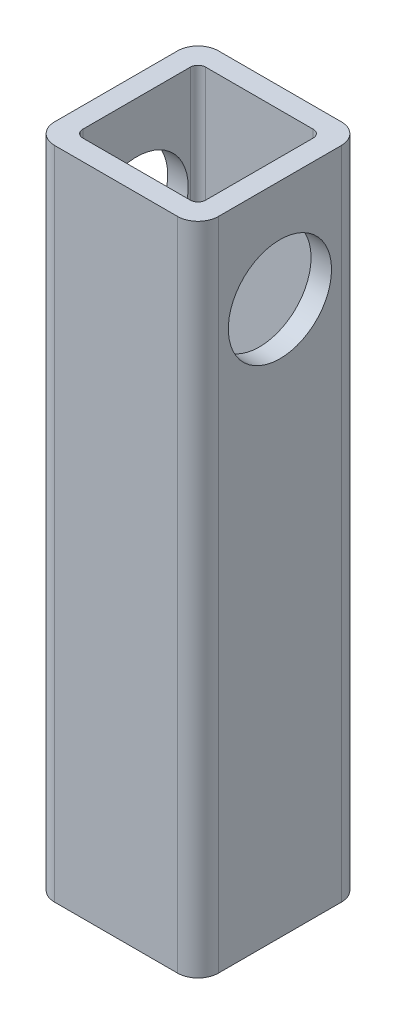
from build123d import *

# Parameters (mm, degrees)
BOSS_EXTRUDE1_DEPTH = 101.6
SKETCH2_R           = 16.002
CUT_EXTRUDE1_DEPTH  = 51.8


with BuildPart() as part:
    # Sketch1 → Boss-Extrude1 (new body, symmetric)
    with BuildSketch(Plane(origin=(0, 0, 0), x_dir=(0, 0, -1), z_dir=(0, 1, 0))):
        with BuildLine():
            Line((-19.05, 25.4), (19.05, 25.4))
            ThreePointArc((19.05, 25.4), (23.540128061, 23.540128061), (25.4, 19.05))
            Line((25.4, 19.05), (25.4, -19.05))
            ThreePointArc((25.4, -19.05), (23.540128061, -23.540128061), (19.05, -25.4))
            Line((19.05, -25.4), (-19.05, -25.4))
            ThreePointArc((-19.05, -25.4), (-23.540128061, -23.540128061), (-25.4, -19.05))
            Line((-25.4, -19.05), (-25.4, 19.05))
            ThreePointArc((-25.4, 19.05), (-23.540128061, 23.540128061), (-19.05, 25.4))
        make_face()
        with BuildLine():
            Line((-16.66875, 19.05), (16.66875, 19.05))
            ThreePointArc((16.66875, 19.05), (18.352548023, 18.352548023), (19.05, 16.66875))
            Line((19.05, 16.66875), (19.05, -16.66875))
            ThreePointArc((19.05, -16.66875), (18.352548023, -18.352548023), (16.66875, -19.05))
            Line((16.66875, -19.05), (-16.66875, -19.05))
            ThreePointArc((-16.66875, -19.05), (-18.352548023, -18.352548023), (-19.05, -16.66875))
            Line((-19.05, -16.66875), (-19.05, 16.66875))
            ThreePointArc((-19.05, 16.66875), (-18.352548023, 18.352548023), (-16.66875, 19.05))
        make_face(mode=Mode.SUBTRACT)
    extrude(amount=BOSS_EXTRUDE1_DEPTH, both=True)

    # Sketch2 → Cut-Extrude1 (cut, through all)
    with BuildSketch(Plane(origin=(25.4, 0, 0), x_dir=(0, 0, -1), z_dir=(1, 0, 0))):
        with Locations((0, 69.85)):
            Circle(SKETCH2_R)
    extrude(amount=-CUT_EXTRUDE1_DEPTH, mode=Mode.SUBTRACT)


solid = part.part
